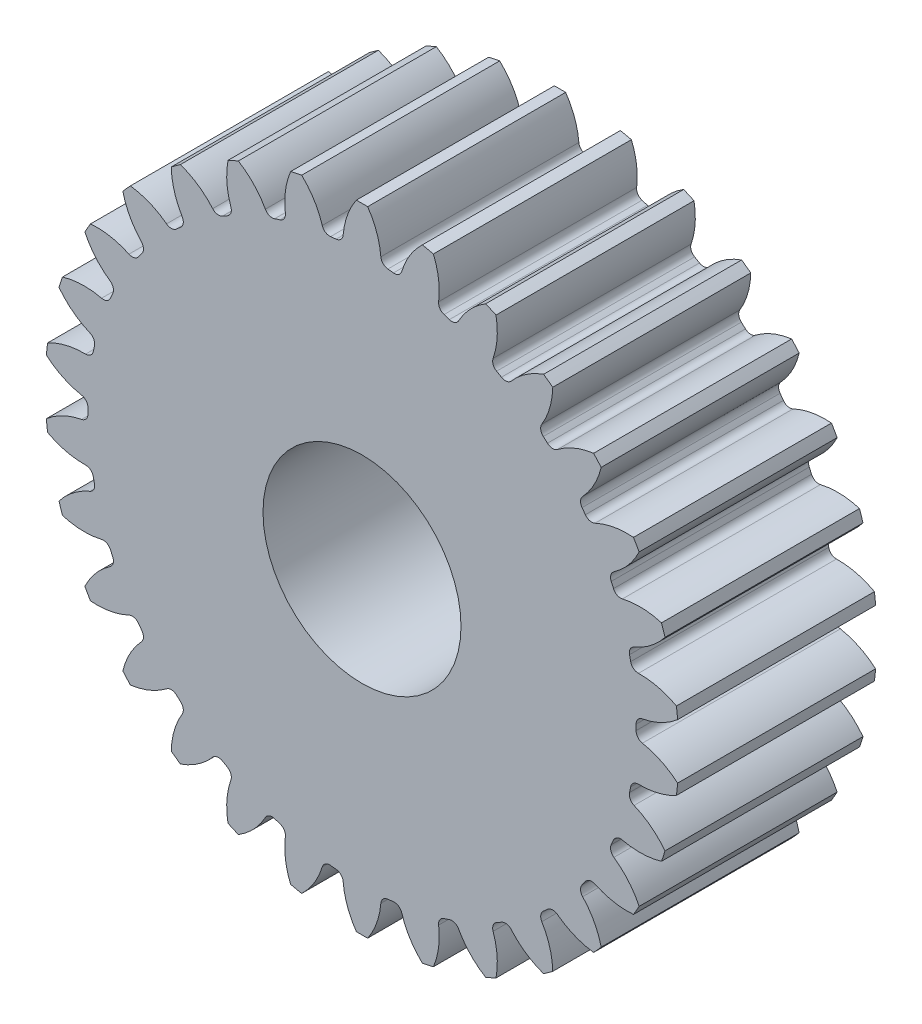
from build123d import *

# Parameters (mm, degrees)
BOSS_EXTRUDE1_DEPTH = 15
CIRPATTERN1_COUNT   = 30
SKETCH5_R           = 20.76438075
BOSS_EXTRUDE2_DEPTH = 15
SKETCH6_R           = 7.5
CUT_EXTRUDE1_DEPTH  = 20


with BuildPart() as part:
    # Sketch4 → Boss-Extrude1 (new body)
    with BuildSketch(Plane.XY):
        with BuildLine():
            ThreePointArc((-1.959580449, 20.671708986), (0, -20.76438075), (1.959580449, 20.671708986))
            ThreePointArc((1.959580449, 20.671708986), (1.596460373, 20.843809755), (1.428197537, 21.208724106))
            ThreePointArc((1.428197537, 21.208724106), (1.110911864, 22.667850953), (0.428788869, 23.99616928))
            ThreePointArc((0.428788869, 23.99616928), (0, 24), (-0.428788869, 23.99616928))
            ThreePointArc((-0.428788869, 23.99616928), (-1.110911864, 22.667850953), (-1.428197537, 21.208724106))
            ThreePointArc((-1.428197537, 21.208724106), (-1.596460373, 20.843809755), (-1.959580449, 20.671708986))
        make_face()
    extrude(amount=BOSS_EXTRUDE1_DEPTH)


with BuildPart() as cirpattern1_1:
    # CirPattern1: pattern copy
    add(part.part.rotate(Axis((0, 0, 0), (0, 0, 1)), 1 * 360 / CIRPATTERN1_COUNT))


with BuildPart() as cirpattern1_2:
    # CirPattern1: pattern copy
    add(part.part.rotate(Axis((0, 0, 0), (0, 0, 1)), 2 * 360 / CIRPATTERN1_COUNT))


with BuildPart() as cirpattern1_3:
    # CirPattern1: pattern copy
    add(part.part.rotate(Axis((0, 0, 0), (0, 0, 1)), 3 * 360 / CIRPATTERN1_COUNT))


with BuildPart() as cirpattern1_4:
    # CirPattern1: pattern copy
    add(part.part.rotate(Axis((0, 0, 0), (0, 0, 1)), 4 * 360 / CIRPATTERN1_COUNT))


with BuildPart() as cirpattern1_5:
    # CirPattern1: pattern copy
    add(part.part.rotate(Axis((0, 0, 0), (0, 0, 1)), 5 * 360 / CIRPATTERN1_COUNT))


with BuildPart() as cirpattern1_6:
    # CirPattern1: pattern copy
    add(part.part.rotate(Axis((0, 0, 0), (0, 0, 1)), 6 * 360 / CIRPATTERN1_COUNT))


with BuildPart() as cirpattern1_7:
    # CirPattern1: pattern copy
    add(part.part.rotate(Axis((0, 0, 0), (0, 0, 1)), 7 * 360 / CIRPATTERN1_COUNT))


with BuildPart() as cirpattern1_8:
    # CirPattern1: pattern copy
    add(part.part.rotate(Axis((0, 0, 0), (0, 0, 1)), 8 * 360 / CIRPATTERN1_COUNT))


with BuildPart() as cirpattern1_9:
    # CirPattern1: pattern copy
    add(part.part.rotate(Axis((0, 0, 0), (0, 0, 1)), 9 * 360 / CIRPATTERN1_COUNT))


with BuildPart() as cirpattern1_10:
    # CirPattern1: pattern copy
    add(part.part.rotate(Axis((0, 0, 0), (0, 0, 1)), 10 * 360 / CIRPATTERN1_COUNT))


with BuildPart() as cirpattern1_11:
    # CirPattern1: pattern copy
    add(part.part.rotate(Axis((0, 0, 0), (0, 0, 1)), 11 * 360 / CIRPATTERN1_COUNT))


with BuildPart() as cirpattern1_12:
    # CirPattern1: pattern copy
    add(part.part.rotate(Axis((0, 0, 0), (0, 0, 1)), 12 * 360 / CIRPATTERN1_COUNT))


with BuildPart() as cirpattern1_13:
    # CirPattern1: pattern copy
    add(part.part.rotate(Axis((0, 0, 0), (0, 0, 1)), 13 * 360 / CIRPATTERN1_COUNT))


with BuildPart() as cirpattern1_14:
    # CirPattern1: pattern copy
    add(part.part.rotate(Axis((0, 0, 0), (0, 0, 1)), 14 * 360 / CIRPATTERN1_COUNT))


with BuildPart() as cirpattern1_15:
    # CirPattern1: pattern copy
    add(part.part.rotate(Axis((0, 0, 0), (0, 0, 1)), 15 * 360 / CIRPATTERN1_COUNT))


with BuildPart() as cirpattern1_16:
    # CirPattern1: pattern copy
    add(part.part.rotate(Axis((0, 0, 0), (0, 0, 1)), 16 * 360 / CIRPATTERN1_COUNT))


with BuildPart() as cirpattern1_17:
    # CirPattern1: pattern copy
    add(part.part.rotate(Axis((0, 0, 0), (0, 0, 1)), 17 * 360 / CIRPATTERN1_COUNT))


with BuildPart() as cirpattern1_18:
    # CirPattern1: pattern copy
    add(part.part.rotate(Axis((0, 0, 0), (0, 0, 1)), 18 * 360 / CIRPATTERN1_COUNT))


with BuildPart() as cirpattern1_19:
    # CirPattern1: pattern copy
    add(part.part.rotate(Axis((0, 0, 0), (0, 0, 1)), 19 * 360 / CIRPATTERN1_COUNT))


with BuildPart() as cirpattern1_20:
    # CirPattern1: pattern copy
    add(part.part.rotate(Axis((0, 0, 0), (0, 0, 1)), 20 * 360 / CIRPATTERN1_COUNT))


with BuildPart() as cirpattern1_21:
    # CirPattern1: pattern copy
    add(part.part.rotate(Axis((0, 0, 0), (0, 0, 1)), 21 * 360 / CIRPATTERN1_COUNT))


with BuildPart() as cirpattern1_22:
    # CirPattern1: pattern copy
    add(part.part.rotate(Axis((0, 0, 0), (0, 0, 1)), 22 * 360 / CIRPATTERN1_COUNT))


with BuildPart() as cirpattern1_23:
    # CirPattern1: pattern copy
    add(part.part.rotate(Axis((0, 0, 0), (0, 0, 1)), 23 * 360 / CIRPATTERN1_COUNT))


with BuildPart() as cirpattern1_24:
    # CirPattern1: pattern copy
    add(part.part.rotate(Axis((0, 0, 0), (0, 0, 1)), 24 * 360 / CIRPATTERN1_COUNT))


with BuildPart() as cirpattern1_25:
    # CirPattern1: pattern copy
    add(part.part.rotate(Axis((0, 0, 0), (0, 0, 1)), 25 * 360 / CIRPATTERN1_COUNT))


with BuildPart() as cirpattern1_26:
    # CirPattern1: pattern copy
    add(part.part.rotate(Axis((0, 0, 0), (0, 0, 1)), 26 * 360 / CIRPATTERN1_COUNT))


with BuildPart() as cirpattern1_27:
    # CirPattern1: pattern copy
    add(part.part.rotate(Axis((0, 0, 0), (0, 0, 1)), 27 * 360 / CIRPATTERN1_COUNT))


with BuildPart() as cirpattern1_28:
    # CirPattern1: pattern copy
    add(part.part.rotate(Axis((0, 0, 0), (0, 0, 1)), 28 * 360 / CIRPATTERN1_COUNT))


with BuildPart() as cirpattern1_29:
    # CirPattern1: pattern copy
    add(part.part.rotate(Axis((0, 0, 0), (0, 0, 1)), 29 * 360 / CIRPATTERN1_COUNT))


with BuildPart() as part_1:
    add(part.part)

    add(cirpattern1_1.part)  # Boss-Extrude2 merges CirPattern1_1

    add(cirpattern1_2.part)  # Boss-Extrude2 merges CirPattern1_2

    add(cirpattern1_3.part)  # Boss-Extrude2 merges CirPattern1_3

    add(cirpattern1_4.part)  # Boss-Extrude2 merges CirPattern1_4

    add(cirpattern1_5.part)  # Boss-Extrude2 merges CirPattern1_5

    add(cirpattern1_6.part)  # Boss-Extrude2 merges CirPattern1_6

    add(cirpattern1_7.part)  # Boss-Extrude2 merges CirPattern1_7

    add(cirpattern1_8.part)  # Boss-Extrude2 merges CirPattern1_8

    add(cirpattern1_9.part)  # Boss-Extrude2 merges CirPattern1_9

    add(cirpattern1_10.part)  # Boss-Extrude2 merges CirPattern1_10

    add(cirpattern1_11.part)  # Boss-Extrude2 merges CirPattern1_11

    add(cirpattern1_12.part)  # Boss-Extrude2 merges CirPattern1_12

    add(cirpattern1_13.part)  # Boss-Extrude2 merges CirPattern1_13

    add(cirpattern1_14.part)  # Boss-Extrude2 merges CirPattern1_14

    add(cirpattern1_15.part)  # Boss-Extrude2 merges CirPattern1_15

    add(cirpattern1_16.part)  # Boss-Extrude2 merges CirPattern1_16

    add(cirpattern1_17.part)  # Boss-Extrude2 merges CirPattern1_17

    add(cirpattern1_18.part)  # Boss-Extrude2 merges CirPattern1_18

    add(cirpattern1_19.part)  # Boss-Extrude2 merges CirPattern1_19

    add(cirpattern1_20.part)  # Boss-Extrude2 merges CirPattern1_20

    add(cirpattern1_21.part)  # Boss-Extrude2 merges CirPattern1_21

    add(cirpattern1_22.part)  # Boss-Extrude2 merges CirPattern1_22

    add(cirpattern1_23.part)  # Boss-Extrude2 merges CirPattern1_23

    add(cirpattern1_24.part)  # Boss-Extrude2 merges CirPattern1_24

    add(cirpattern1_25.part)  # Boss-Extrude2 merges CirPattern1_25

    add(cirpattern1_26.part)  # Boss-Extrude2 merges CirPattern1_26

    add(cirpattern1_27.part)  # Boss-Extrude2 merges CirPattern1_27

    add(cirpattern1_28.part)  # Boss-Extrude2 merges CirPattern1_28

    add(cirpattern1_29.part)  # Boss-Extrude2 merges CirPattern1_29
    # Sketch5 → Boss-Extrude2 (add)
    with BuildSketch(Plane.XY.offset(15)):
        Circle(SKETCH5_R)
    extrude(amount=-BOSS_EXTRUDE2_DEPTH)

    # Sketch6 → Cut-Extrude1 (cut)
    with BuildSketch(Plane.XY.offset(15)):
        Circle(SKETCH6_R)
    extrude(amount=-CUT_EXTRUDE1_DEPTH, mode=Mode.SUBTRACT)


solid = part_1.part
